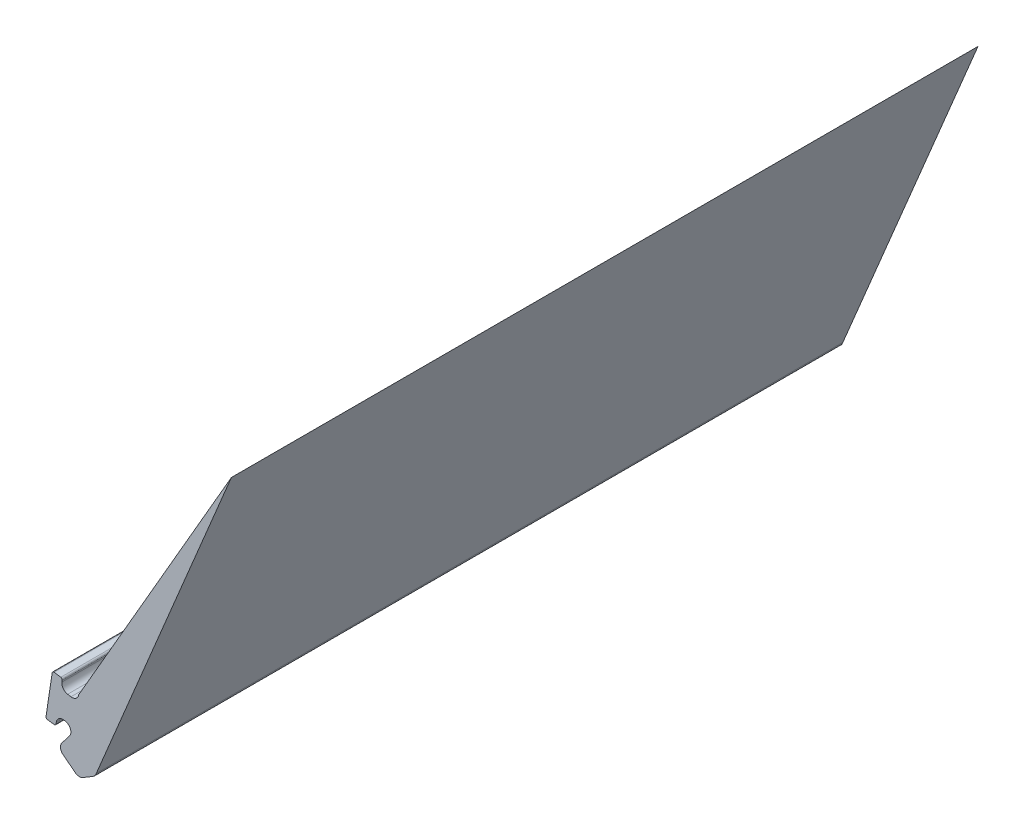
from build123d import *

# Parameters (mm, degrees)
BOSS_EXTRUDE1_DEPTH = 22


with BuildPart() as part:
    # Sketch1 → Boss-Extrude1 (new body)
    with BuildSketch(Plane.XY):
        with BuildLine():
            Line((-21.35205925, 11.1154812), (-17.368827213, 20.661456443))
            Line((-17.368827213, 20.661456443), (-21.868827213, 12.867227809))
            ThreePointArc((-21.868827213, 12.867227809), (-21.948667572, 12.73617279), (-22.097868544, 12.700270549))
            Line((-22.097868544, 12.700270549), (-22.196215152, 12.715900014))
            ThreePointArc((-22.196215152, 12.715900014), (-22.326689682, 12.79594909), (-22.362345861, 12.94481176))
            Line((-22.362345861, 12.94481176), (-22.354687101, 12.993003628))
            ThreePointArc((-22.354687101, 12.993003628), (-22.363718798, 13.030380728), (-22.396614586, 13.050292692))
            Line((-22.396614586, 13.050292692), (-22.592962298, 13.079890225))
            ThreePointArc((-22.592962298, 13.079890225), (-22.630105552, 13.070679105), (-22.649856554, 13.037901612))
            Line((-22.649856554, 13.037901612), (-22.832052004, 11.829231305))
            ThreePointArc((-22.832052004, 11.829231305), (-22.822704304, 11.791903872), (-22.789609619, 11.772270774))
            Line((-22.789609619, 11.772270774), (-22.592446198, 11.744397206))
            ThreePointArc((-22.592446198, 11.744397206), (-22.555388987, 11.753948603), (-22.535939439, 11.786905866))
            Line((-22.535939439, 11.786905866), (-22.529535655, 11.832202971))
            ThreePointArc((-22.529535655, 11.832202971), (-22.448384623, 11.96650006), (-22.295290569, 12.00090077))
            Line((-22.295290569, 12.00090077), (-22.264046695, 11.995148315))
            ThreePointArc((-22.264046695, 11.995148315), (-22.113475119, 11.869945968), (-22.141972438, 11.6762056))
            Line((-22.141972438, 11.6762056), (-22.365452219, 11.3868424))
            ThreePointArc((-22.365452219, 11.3868424), (-22.405533487, 11.239109704), (-22.329412432, 11.106305176))
            Line((-22.329412432, 11.106305176), (-21.969472499, 10.828317868))
            ThreePointArc((-21.969472499, 10.828317868), (-21.858721207, 10.786937123), (-21.743952077, 10.81533187))
            Line((-21.743952077, 10.81533187), (-21.441501697, 10.997697404))
            ThreePointArc((-21.441501697, 10.997697404), (-21.385493263, 11.048018041), (-21.35205925, 11.1154812))
        make_face()
    extrude(amount=-BOSS_EXTRUDE1_DEPTH)


solid = part.part
